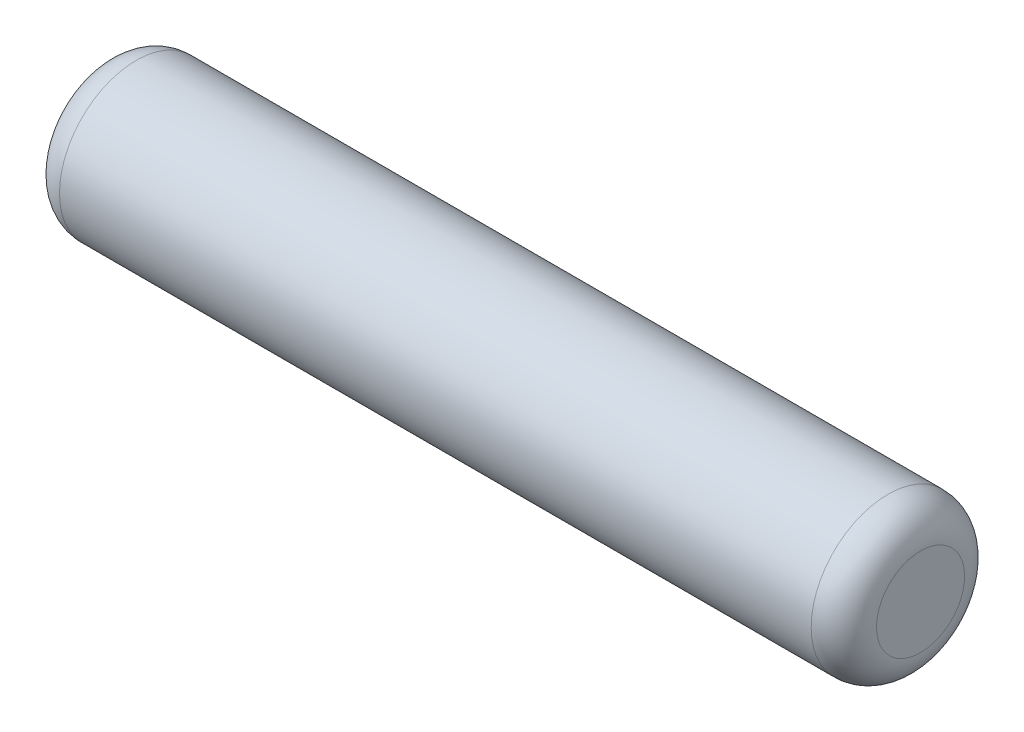
from build123d import *


with BuildPart() as part:
    # Sketch1 → Base-Revolve (revolve)
    with BuildSketch(Plane.XY):
        with BuildLine():
            Line((0, 0), (12.7, 0))
            Line((12.7, 0), (12.7, 0.68453))
            ThreePointArc((12.7, 0.68453), (12.551210245, 1.043740245), (12.192, 1.19253))
            Line((12.192, 1.19253), (0.508, 1.19253))
            ThreePointArc((0.508, 1.19253), (0.148789755, 1.043740245), (0, 0.68453))
            Line((0, 0.68453), (0, 0))
        make_face()
    revolve(axis=Axis((-6.35, 0, 0), (1, 0, 0)))


solid = part.part
